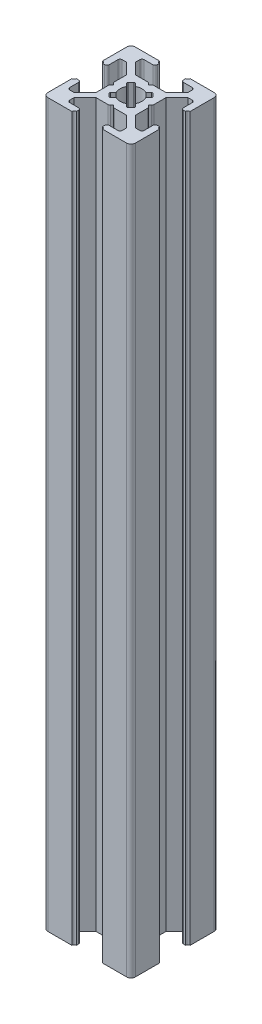
from build123d import *

# Parameters (mm, degrees)
BOSS_EXTRUDE1_DEPTH = 165
FILLET1_R           = 1
CUT_EXTRUDE1_DEPTH  = 166
FILLET2_R           = 0.5
FILLET3_R           = 0.25


with BuildPart() as part:
    # Sketch3 → Boss-Extrude1 (new body)
    with BuildSketch(Plane(origin=(0, 0, 0), x_dir=(1, 0, 0), z_dir=(0, 1, 0))):
        with BuildLine():
            Line((7, 18.5), (7, 19.5))
            ThreePointArc((7, 19.5), (6.646446609, 19.646446609), (6.5, 20))
            Line((6.5, 20), (0, 20))
            Line((0, 20), (0, 13.5))
            ThreePointArc((0, 13.5), (0.353553391, 13.353553391), (0.5, 13))
            Line((0.5, 13), (1.5, 13))
            Line((1.5, 13), (1.5, 16))
            Line((1.5, 16), (3, 16))
            Line((3, 16), (5.5, 13.5))
            Line((5.5, 13.5), (5.5, 10.5))
            Line((5.5, 10.5), (6, 10))
            Line((6, 10), (5.5, 9.5))
            Line((5.5, 9.5), (5.5, 6.5))
            Line((5.5, 6.5), (3, 4))
            Line((3, 4), (1.5, 4))
            Line((1.5, 4), (1.5, 7))
            Line((1.5, 7), (0.5, 7))
            ThreePointArc((0.5, 7), (0.353553391, 6.646446609), (0, 6.5))
            Line((0, 6.5), (0, 0))
            Line((0, 0), (6.5, 0))
            ThreePointArc((6.5, 0), (6.646446609, 0.353553391), (7, 0.5))
            Line((7, 0.5), (7, 1.5))
            Line((7, 1.5), (4, 1.5))
            Line((4, 1.5), (4, 3))
            Line((4, 3), (6.5, 5.5))
            Line((6.5, 5.5), (9.5, 5.5))
            Line((9.5, 5.5), (10, 6))
            Line((10, 6), (10.5, 5.5))
            Line((10.5, 5.5), (13.5, 5.5))
            Line((13.5, 5.5), (16, 3))
            Line((16, 3), (16, 1.5))
            Line((16, 1.5), (13, 1.5))
            Line((13, 1.5), (13, 0.5))
            ThreePointArc((13, 0.5), (13.353553391, 0.353553391), (13.5, 0))
            Line((13.5, 0), (20, 0))
            Line((20, 0), (20, 6.5))
            ThreePointArc((20, 6.5), (19.646446609, 6.646446609), (19.5, 7))
            Line((19.5, 7), (18.5, 7))
            Line((18.5, 7), (18.5, 4))
            Line((18.5, 4), (17, 4))
            Line((17, 4), (14.5, 6.5))
            Line((14.5, 6.5), (14.5, 9.5))
            Line((14.5, 9.5), (14, 10))
            Line((14, 10), (14.5, 10.5))
            Line((14.5, 10.5), (14.5, 13.5))
            Line((14.5, 13.5), (17, 16))
            Line((17, 16), (18.5, 16))
            Line((18.5, 16), (18.5, 13))
            Line((18.5, 13), (19.5, 13))
            ThreePointArc((19.5, 13), (19.646446609, 13.353553391), (20, 13.5))
            Line((20, 13.5), (20, 20))
            Line((20, 20), (13.5, 20))
            ThreePointArc((13.5, 20), (13.353553391, 19.646446609), (13, 19.5))
            Line((13, 19.5), (13, 18.5))
            Line((13, 18.5), (16, 18.5))
            Line((16, 18.5), (16, 17))
            Line((16, 17), (13.5, 14.5))
            Line((13.5, 14.5), (10.5, 14.5))
            Line((10.5, 14.5), (10, 14))
            Line((10, 14), (9.5, 14.5))
            Line((9.5, 14.5), (6.5, 14.5))
            Line((6.5, 14.5), (4, 17))
            Line((4, 17), (4, 18.5))
            Line((4, 18.5), (7, 18.5))
        make_face()
    extrude(amount=BOSS_EXTRUDE1_DEPTH)

    # Fillet1
    fillet1_edges = [part.edges().sort_by_distance(p)[0] for p in [
        (20, 82.5, 0),
        (0, 82.5, 0),
        (0, 82.5, -20),
        (20, 82.5, -20),
    ]]
    fillet(fillet1_edges, radius=FILLET1_R)

    # Sketch4 → Cut-Extrude1 (cut, through all)
    with BuildSketch(Plane(origin=(0, 165, 0), x_dir=(1, 0, 0), z_dir=(0, 1, 0))):
        with BuildLine():
            Line((10, 11), (11.195582496, 12.195582496))
            ThreePointArc((11.195582496, 12.195582496), (10, 12.5), (8.804417504, 12.195582496))
            Line((8.804417504, 12.195582496), (10, 11))
        make_face()
        with BuildLine():
            ThreePointArc((12.195582496, 11.195582496), (11.767766953, 11.767766953), (11.195582496, 12.195582496))
            Line((11.195582496, 12.195582496), (10, 11))
            Line((10, 11), (11, 10))
            Line((11, 10), (12.195582496, 11.195582496))
        make_face()
        with BuildLine():
            Line((9, 10), (10, 11))
            Line((10, 11), (8.804417504, 12.195582496))
            ThreePointArc((8.804417504, 12.195582496), (8.232233047, 11.767766953), (7.804417504, 11.195582496))
            Line((7.804417504, 11.195582496), (9, 10))
        make_face()
        Polygon((11, 10), (10, 11), (9, 10), (10, 9), align=None)
        with BuildLine():
            Line((7.804417504, 8.804417504), (9, 10))
            Line((9, 10), (7.804417504, 11.195582496))
            ThreePointArc((7.804417504, 11.195582496), (7.5, 10), (7.804417504, 8.804417504))
        make_face()
        with BuildLine():
            Line((10, 9), (9, 10))
            Line((9, 10), (7.804417504, 8.804417504))
            ThreePointArc((7.804417504, 8.804417504), (8.232233047, 8.232233047), (8.804417504, 7.804417504))
            Line((8.804417504, 7.804417504), (10, 9))
        make_face()
        with BuildLine():
            Line((11.195582496, 7.804417504), (10, 9))
            Line((10, 9), (8.804417504, 7.804417504))
            ThreePointArc((8.804417504, 7.804417504), (10, 7.5), (11.195582496, 7.804417504))
        make_face()
        with BuildLine():
            Line((12.195582496, 8.804417504), (11, 10))
            Line((11, 10), (10, 9))
            Line((10, 9), (11.195582496, 7.804417504))
            ThreePointArc((11.195582496, 7.804417504), (11.767766953, 8.232233047), (12.195582496, 8.804417504))
        make_face()
        with BuildLine():
            ThreePointArc((12.5, 10), (12.422700584, 10.616864556), (12.195582496, 11.195582496))
            Line((12.195582496, 11.195582496), (11, 10))
            Line((11, 10), (12.195582496, 8.804417504))
            ThreePointArc((12.195582496, 8.804417504), (12.422700584, 9.383135444), (12.5, 10))
        make_face()
        with BuildLine():
            ThreePointArc((8.804417504, 7.804417504), (8.232233047, 8.232233047), (7.804417504, 8.804417504))
            Line((7.804417504, 8.804417504), (7, 8))
            Line((7, 8), (8, 7))
            Line((8, 7), (8.804417504, 7.804417504))
        make_face()
        with BuildLine():
            Line((13, 8), (12.195582496, 8.804417504))
            ThreePointArc((12.195582496, 8.804417504), (11.767766953, 8.232233047), (11.195582496, 7.804417504))
            Line((11.195582496, 7.804417504), (12, 7))
            Line((12, 7), (13, 8))
        make_face()
        with BuildLine():
            Line((13, 12), (12, 13))
            Line((12, 13), (11.195582496, 12.195582496))
            ThreePointArc((11.195582496, 12.195582496), (11.767766953, 11.767766953), (12.195582496, 11.195582496))
            Line((12.195582496, 11.195582496), (13, 12))
        make_face()
        with BuildLine():
            ThreePointArc((7.804417504, 11.195582496), (8.232233047, 11.767766953), (8.804417504, 12.195582496))
            Line((8.804417504, 12.195582496), (8, 13))
            Line((8, 13), (7, 12))
            Line((7, 12), (7.804417504, 11.195582496))
        make_face()
    extrude(amount=-CUT_EXTRUDE1_DEPTH, mode=Mode.SUBTRACT)

    # Fillet2
    fillet2_edges = [part.edges().sort_by_distance(p)[0] for p in [
        (18.5, 82.5, -13),
        (18.5, 82.5, -16),
        (14.5, 82.5, -10.5),
        (14.5, 82.5, -9.5),
        (18.5, 82.5, -4),
        (18.5, 82.5, -7),
        (13, 82.5, -1.5),
        (16, 82.5, -1.5),
        (10.5, 82.5, -5.5),
        (9.5, 82.5, -5.5),
        (4, 82.5, -1.5),
        (7, 82.5, -1.5),
        (1.5, 82.5, -7),
        (1.5, 82.5, -4),
        (5.5, 82.5, -9.5),
        (5.5, 82.5, -10.5),
        (1.5, 82.5, -16),
        (1.5, 82.5, -13),
        (7, 82.5, -18.5),
        (4, 82.5, -18.5),
        (9.5, 82.5, -14.5),
        (10.5, 82.5, -14.5),
        (16, 82.5, -18.5),
        (13, 82.5, -18.5),
    ]]
    fillet(fillet2_edges, radius=FILLET2_R)

    # Fillet3
    fillet3_edges = [part.edges().sort_by_distance(p)[0] for p in [
        (7, 82.5, -12),
        (8, 82.5, -13),
        (12, 82.5, -13),
        (13, 82.5, -12),
        (13, 82.5, -8),
        (12, 82.5, -7),
        (8, 82.5, -7),
        (7, 82.5, -8),
    ]]
    fillet(fillet3_edges, radius=FILLET3_R)


solid = part.part
